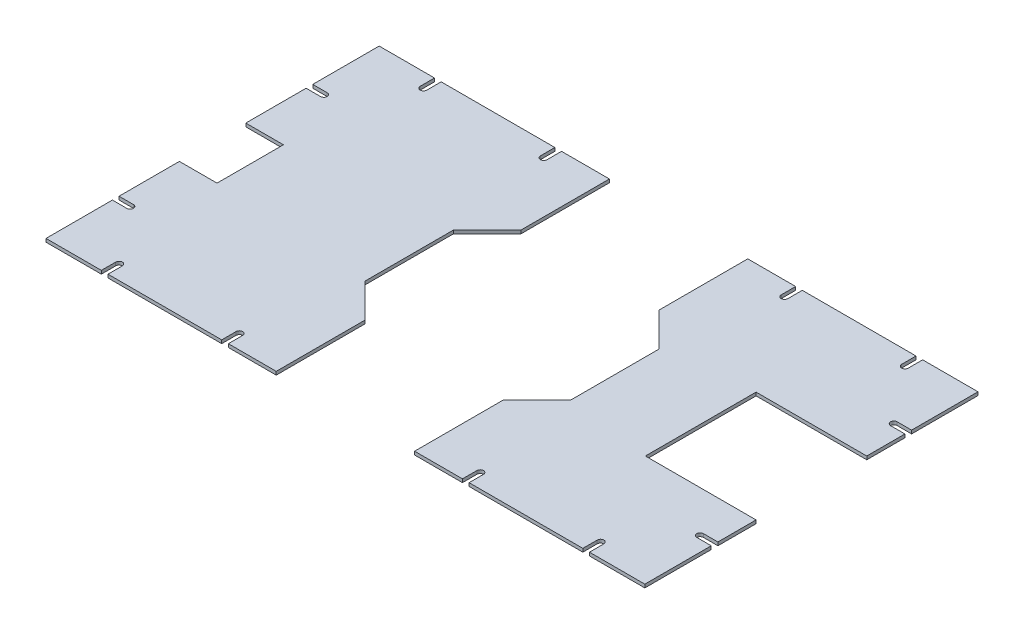
from build123d import *

# Parameters (mm, degrees)
SKETCH1_W           = 541
SKETCH1_H           = 301
BOSS_EXTRUDE1_DEPTH = 3
SKETCH2_W           = 34
SKETCH2_H           = 60
CUT_EXTRUDE1_DEPTH  = 10
SKETCH3_W           = 200
SKETCH3_H           = 100
CUT_EXTRUDE2_DEPTH  = 5
SKETCH4_W           = 125
SKETCH4_H           = 301
CUT_EXTRUDE3_DEPTH  = 5
CUT_EXTRUDE4_DEPTH  = 10
CUT_EXTRUDE5_DEPTH  = 10


with BuildPart() as part:
    # Sketch1 → Boss-Extrude1 (new body)
    with BuildSketch(Plane(origin=(0, 0, 0), x_dir=(1, 0, 0), z_dir=(0, 1, 0))):
        Rectangle(SKETCH1_W, SKETCH1_H)
    extrude(amount=BOSS_EXTRUDE1_DEPTH)

    # Sketch2 → Cut-Extrude1 (cut)
    with BuildSketch(Plane.XZ):
        with Locations((-253.5, 0)):
            Rectangle(SKETCH2_W, SKETCH2_H)
    extrude(amount=-CUT_EXTRUDE1_DEPTH, mode=Mode.SUBTRACT)

    # Sketch3 → Cut-Extrude2 (cut)
    with BuildSketch(Plane.XZ):
        with Locations((270.5, 0)):
            Rectangle(SKETCH3_W, SKETCH3_H)
    extrude(amount=-CUT_EXTRUDE2_DEPTH, mode=Mode.SUBTRACT)

    # Sketch4 → Cut-Extrude3 (cut)
    with BuildSketch(Plane(origin=(0, 3, 0), x_dir=(1, 0, 0), z_dir=(0, 1, 0))):
        Rectangle(SKETCH4_W, SKETCH4_H)
    extrude(amount=-CUT_EXTRUDE3_DEPTH, mode=Mode.SUBTRACT)

    # Sketch5 → Cut-Extrude4 (cut)
    with BuildSketch(Plane(origin=(0, 3, 0), x_dir=(1, 0, 0), z_dir=(0, 1, 0))):
        with BuildLine():
            Line((-270.5, -84.5), (-270.5, -90.5))
            Line((-270.5, -90.5), (-257.5, -90.5))
            ThreePointArc((-257.5, -90.5), (-254.5, -87.5), (-257.5, -84.5))
            Line((-257.5, -84.5), (-270.5, -84.5))
        make_face()
        with BuildLine():
            Line((-111.75, -150.5), (-105.75, -150.5))
            Line((-105.75, -150.5), (-105.75, -137.5))
            ThreePointArc((-105.75, -137.5), (-108.75, -134.5), (-111.75, -137.5))
            Line((-111.75, -137.5), (-111.75, -150.5))
        make_face()
        with BuildLine():
            Line((-257.5, 90.5), (-270.5, 90.5))
            Line((-270.5, 90.5), (-270.5, 84.5))
            Line((-270.5, 84.5), (-257.5, 84.5))
            ThreePointArc((-257.5, 84.5), (-254.5, 87.5), (-257.5, 90.5))
        make_face()
        with BuildLine():
            Line((-214.5, 150.5), (-220.5, 150.5))
            Line((-220.5, 150.5), (-220.5, 137.5))
            ThreePointArc((-220.5, 137.5), (-217.5, 134.5), (-214.5, 137.5))
            Line((-214.5, 137.5), (-214.5, 150.5))
        make_face()
        with BuildLine():
            Line((105.75, 150.5), (105.75, 137.5))
            ThreePointArc((105.75, 137.5), (108.75, 134.5), (111.75, 137.5))
            Line((111.75, 137.5), (111.75, 150.5))
            Line((111.75, 150.5), (105.75, 150.5))
        make_face()
        with BuildLine():
            Line((214.5, 150.5), (214.5, 137.5))
            ThreePointArc((214.5, 137.5), (217.5, 134.5), (220.5, 137.5))
            Line((220.5, 137.5), (220.5, 150.5))
            Line((220.5, 150.5), (214.5, 150.5))
        make_face()
        with BuildLine():
            Line((270.5, 90.5), (257.5, 90.5))
            ThreePointArc((257.5, 90.5), (254.5, 87.5), (257.5, 84.5))
            Line((257.5, 84.5), (270.5, 84.5))
            Line((270.5, 84.5), (270.5, 90.5))
        make_face()
        with BuildLine():
            ThreePointArc((257.5, -90.5), (254.5, -87.5), (257.5, -84.5))
            Line((257.5, -84.5), (270.5, -84.5))
            Line((270.5, -84.5), (270.5, -90.5))
            Line((270.5, -90.5), (257.5, -90.5))
        make_face()
        with BuildLine():
            ThreePointArc((214.5, -137.5), (217.5, -134.5), (220.5, -137.5))
            Line((220.5, -137.5), (220.5, -150.5))
            Line((220.5, -150.5), (214.5, -150.5))
            Line((214.5, -150.5), (214.5, -137.5))
        make_face()
        with BuildLine():
            ThreePointArc((105.75, -137.5), (108.75, -134.5), (111.75, -137.5))
            Line((111.75, -137.5), (111.75, -150.5))
            Line((111.75, -150.5), (105.75, -150.5))
            Line((105.75, -150.5), (105.75, -137.5))
        make_face()
        with BuildLine():
            Line((-214.5, -137.5), (-214.5, -150.5))
            Line((-214.5, -150.5), (-220.5, -150.5))
            Line((-220.5, -150.5), (-220.5, -137.5))
            ThreePointArc((-220.5, -137.5), (-217.5, -134.5), (-214.5, -137.5))
        make_face()
        with BuildLine():
            Line((-105.75, 137.5), (-105.75, 150.5))
            Line((-105.75, 150.5), (-111.75, 150.5))
            Line((-111.75, 150.5), (-111.75, 137.5))
            ThreePointArc((-111.75, 137.5), (-108.75, 134.5), (-105.75, 137.5))
        make_face()
    extrude(amount=-CUT_EXTRUDE4_DEPTH, mode=Mode.SUBTRACT)

    # Sketch6 → Cut-Extrude5 (cut)
    with BuildSketch(Plane(origin=(0, 3, 0), x_dir=(1, 0, 0), z_dir=(0, 1, 0))):
        Polygon((62.5, 150.5), (-62.5, 150.5), (-62.5, 70.5), (-93, 40), (-93, -40), (-62.5, -70.5), (-62.5, -150.5), (62.5, -150.5), (62.5, -70.5), (93, -40), (93, 40), (62.5, 70.5), align=None)
    extrude(amount=-CUT_EXTRUDE5_DEPTH, mode=Mode.SUBTRACT)


solid = part.part
